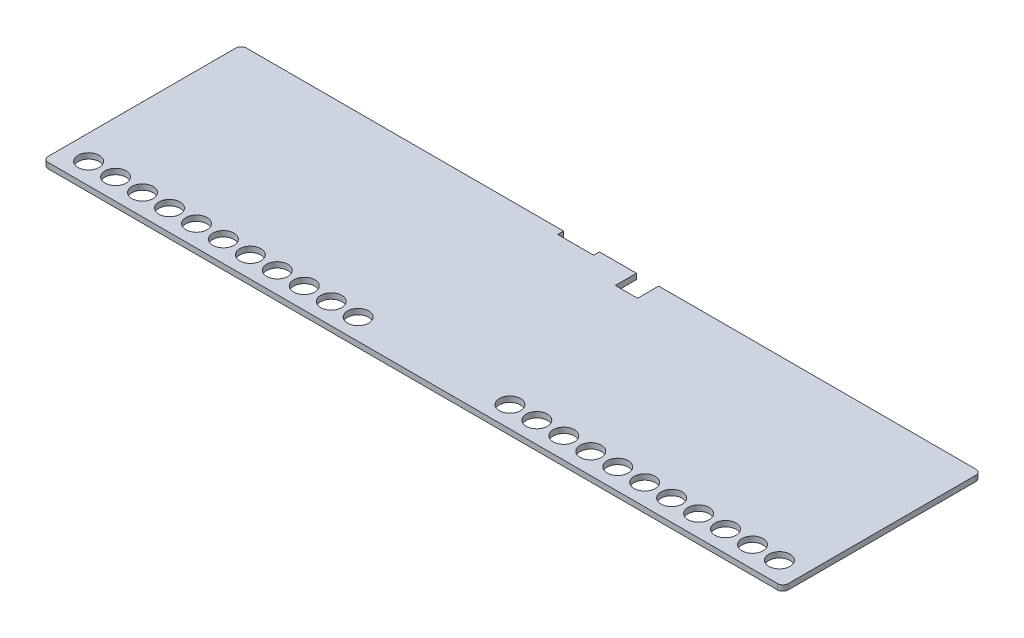
from build123d import *

# Parameters (mm, degrees)
SKETCH1_R           = 2.0025
BOSS_EXTRUDE1_DEPTH = 1.05
SKETCH3_R           = 1.5025
SKETCH3_W           = 5.005
SKETCH3_H           = 4.005
CUT_EXTRUDE8_DEPTH  = 0.85


with BuildPart() as part:
    # Sketch1 → Boss-Extrude1 (new body)
    with BuildSketch(Plane(origin=(0, 0, 0), x_dir=(1, 0, 0), z_dir=(0, 1, 0))):
        with BuildLine():
            Line((-69, 18.75), (-9, 18.75))
            Line((-9, 18.75), (-9, 17.65))
            Line((-9, 17.65), (-2.2, 17.65))
            Line((-2.2, 17.65), (-2.2, 18.75))
            Line((-2.2, 18.75), (4.8, 18.75))
            Line((4.8, 18.75), (4.8, 14.75))
            Line((4.8, 14.75), (9, 14.75))
            Line((9, 14.75), (9, 18.75))
            Line((9, 18.75), (69, 18.75))
            ThreePointArc((69, 18.75), (69.707106781, 18.457106781), (70, 17.75))
            Line((70, 17.75), (70, -17.75))
            ThreePointArc((70, -17.75), (69.707106781, -18.457106781), (69, -18.75))
            Line((69, -18.75), (-69, -18.75))
            ThreePointArc((-69, -18.75), (-69.707106781, -18.457106781), (-70, -17.75))
            Line((-70, -17.75), (-70, 17.75))
            ThreePointArc((-70, 17.75), (-69.707106781, 18.457106781), (-69, 18.75))
        make_face()
        with Locations((-65.35, -14.75)):
            Circle(SKETCH1_R, mode=Mode.SUBTRACT)
        with Locations((-60.25, -14.75)):
            Circle(SKETCH1_R, mode=Mode.SUBTRACT)
        with Locations((-55.15, -14.75)):
            Circle(SKETCH1_R, mode=Mode.SUBTRACT)
        with Locations((-50.05, -14.75)):
            Circle(SKETCH1_R, mode=Mode.SUBTRACT)
        with Locations((-44.95, -14.75)):
            Circle(SKETCH1_R, mode=Mode.SUBTRACT)
        with Locations((-39.85, -14.75)):
            Circle(SKETCH1_R, mode=Mode.SUBTRACT)
        with Locations((-34.75, -14.75)):
            Circle(SKETCH1_R, mode=Mode.SUBTRACT)
        with Locations((-29.65, -14.75)):
            Circle(SKETCH1_R, mode=Mode.SUBTRACT)
        with Locations((-24.55, -14.75)):
            Circle(SKETCH1_R, mode=Mode.SUBTRACT)
        with Locations((-19.45, -14.75)):
            Circle(SKETCH1_R, mode=Mode.SUBTRACT)
        with Locations((-14.35, -14.75)):
            Circle(SKETCH1_R, mode=Mode.SUBTRACT)
        with Locations((65.35, -14.75)):
            Circle(SKETCH1_R, mode=Mode.SUBTRACT)
        with Locations((60.25, -14.75)):
            Circle(SKETCH1_R, mode=Mode.SUBTRACT)
        with Locations((55.15, -14.75)):
            Circle(SKETCH1_R, mode=Mode.SUBTRACT)
        with Locations((50.05, -14.75)):
            Circle(SKETCH1_R, mode=Mode.SUBTRACT)
        with Locations((44.95, -14.75)):
            Circle(SKETCH1_R, mode=Mode.SUBTRACT)
        with Locations((39.85, -14.75)):
            Circle(SKETCH1_R, mode=Mode.SUBTRACT)
        with Locations((34.75, -14.75)):
            Circle(SKETCH1_R, mode=Mode.SUBTRACT)
        with Locations((29.65, -14.75)):
            Circle(SKETCH1_R, mode=Mode.SUBTRACT)
        with Locations((24.55, -14.75)):
            Circle(SKETCH1_R, mode=Mode.SUBTRACT)
        with Locations((19.45, -14.75)):
            Circle(SKETCH1_R, mode=Mode.SUBTRACT)
        with Locations((14.35, -14.75)):
            Circle(SKETCH1_R, mode=Mode.SUBTRACT)
    extrude(amount=-BOSS_EXTRUDE1_DEPTH)

    # Sketch3 → Cut-Extrude8 (cut)
    with BuildSketch(Plane.XZ.offset(1.05)):
        with Locations((62.23, -8.1425)):
            Circle(SKETCH3_R)
        with Locations((44.45, -8.1425)):
            Circle(SKETCH3_R)
        with Locations((26.67, -8.1425)):
            Circle(SKETCH3_R)
        with Locations((8.89, -8.1425)):
            Circle(SKETCH3_R)
        with Locations((-8.89, -8.1425)):
            Circle(SKETCH3_R)
        with Locations((-26.67, -8.1425)):
            Circle(SKETCH3_R)
        with Locations((-44.45, -8.1425)):
            Circle(SKETCH3_R)
        with Locations((-62.23, -8.1425)):
            Circle(SKETCH3_R)
        with Locations((62.2275, 0.7475)):
            Rectangle(SKETCH3_W, SKETCH3_H)
        with Locations((44.4475, 0.7475)):
            Rectangle(SKETCH3_W, SKETCH3_H)
        with Locations((26.6675, 0.7475)):
            Rectangle(SKETCH3_W, SKETCH3_H)
        with Locations((8.8875, 0.7475)):
            Rectangle(SKETCH3_W, SKETCH3_H)
        with Locations((-8.8925, 0.7475)):
            Rectangle(SKETCH3_W, SKETCH3_H)
        with Locations((-26.6725, 0.7475)):
            Rectangle(SKETCH3_W, SKETCH3_H)
        with Locations((-44.4525, 0.7475)):
            Rectangle(SKETCH3_W, SKETCH3_H)
        with Locations((-62.2325, 0.7475)):
            Rectangle(SKETCH3_W, SKETCH3_H)
    extrude(amount=-CUT_EXTRUDE8_DEPTH, mode=Mode.SUBTRACT)


solid = part.part
